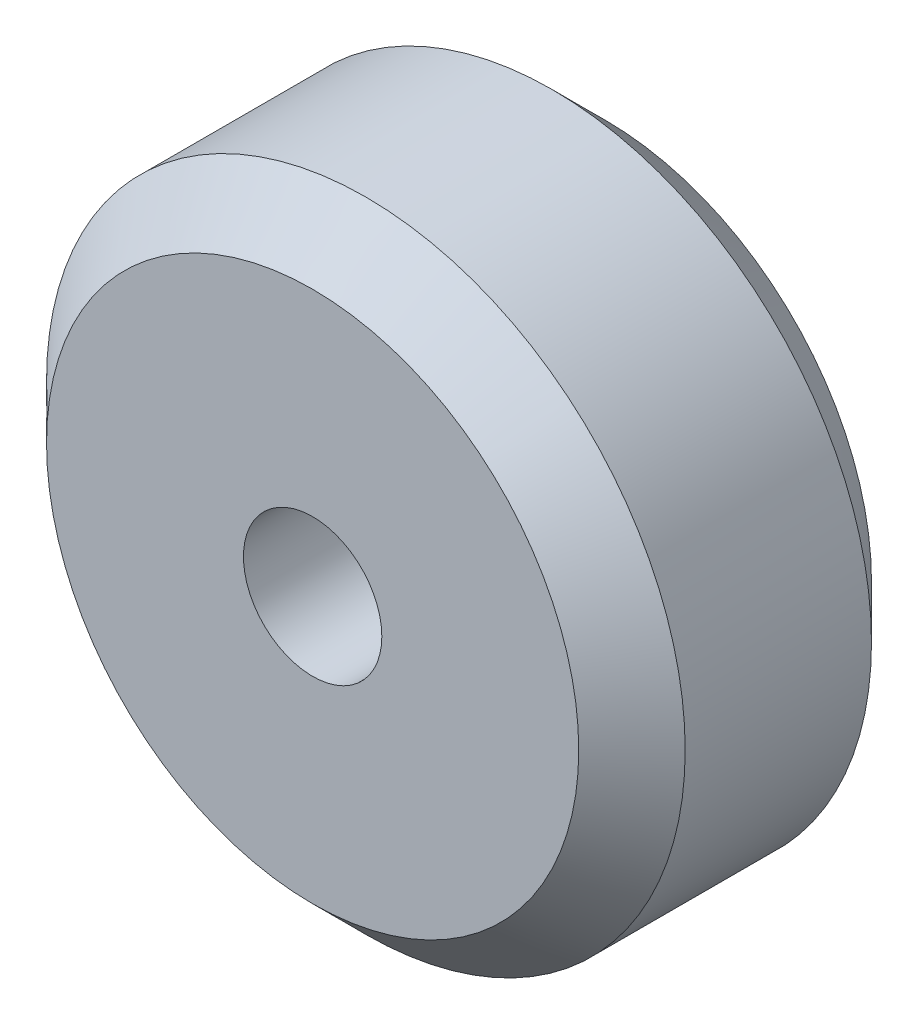
from build123d import *

# Parameters (mm, degrees)
SKETCH1_R           = 12
BOSS_EXTRUDE1_DEPTH = 11
CHAMFER1_SIZE       = 2
SKETCH2_R           = 2.6
CUT_EXTRUDE1_DEPTH  = 11


with BuildPart() as part:
    # Sketch1 → Boss-Extrude1 (new body)
    with BuildSketch(Plane.XY):
        Circle(SKETCH1_R)
    extrude(amount=BOSS_EXTRUDE1_DEPTH)

    # Chamfer1
    chamfer1_edges = [part.edges().sort_by_distance(p)[0] for p in [
        (-12, 0, 0),
        (-12, 0, 11),
    ]]
    chamfer(chamfer1_edges, length=CHAMFER1_SIZE)

    # Sketch2 → Cut-Extrude1 (cut)
    with BuildSketch(Plane.XY.offset(11)):
        Circle(SKETCH2_R)
    extrude(amount=-CUT_EXTRUDE1_DEPTH, mode=Mode.SUBTRACT)


solid = part.part
